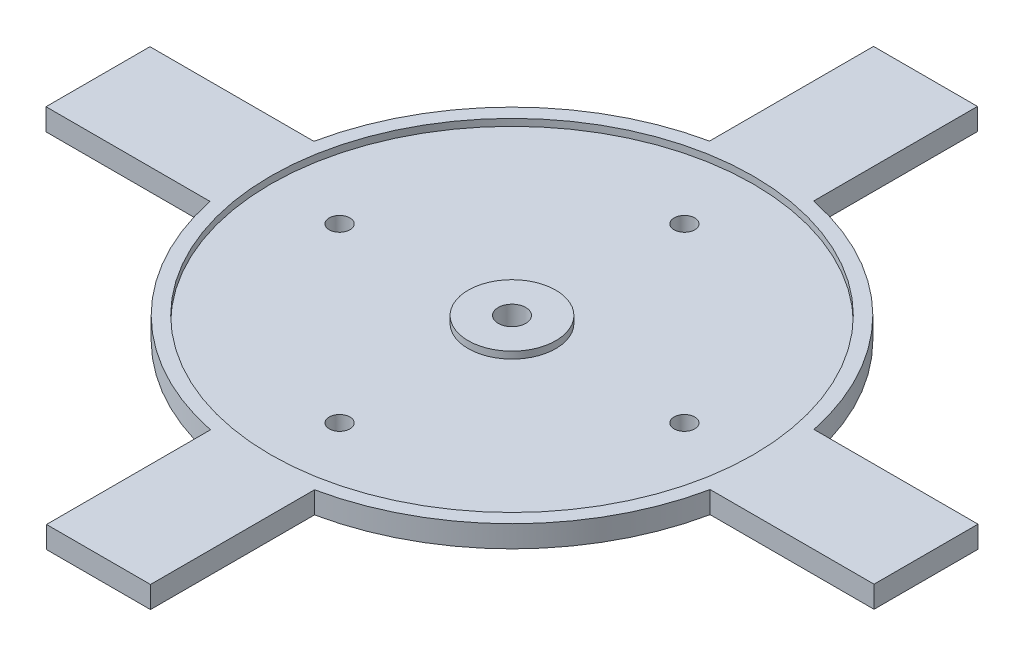
from build123d import *

# Parameters (mm, degrees)
SKETCH1_R           = 37
BOSS_EXTRUDE1_DEPTH = 3.158172797
SKETCH13_W          = 7.575673387
SKETCH13_H          = 3.158172797
SKETCH13_W_2        = 7.5
BOSS_EXTRUDE2_DEPTH = 60
CIRPATTERN1_COUNT   = 4
SKETCH2_R           = 35
SKETCH2_R_2         = 6.35
CUT_EXTRUDE1_DEPTH  = 1
SKETCH17_R          = 2
CUT_EXTRUDE2_DEPTH  = 10
SKETCH19_R          = 1.5
CUT_EXTRUDE3_DEPTH  = 10
CIRPATTERN2_COUNT   = 4


with BuildPart() as part:
    # Sketch1 → Boss-Extrude1 (new body)
    with BuildSketch(Plane(origin=(0, 0, 0), x_dir=(1, 0, 0), z_dir=(0, 1, 0))):
        Circle(SKETCH1_R)
    extrude(amount=BOSS_EXTRUDE1_DEPTH)

    # Sketch13 → Boss-Extrude2 (add)
    with BuildSketch(Plane.XY):
        with Locations((3.787836694, 1.579086399)):
            Rectangle(SKETCH13_W, SKETCH13_H)
        with Locations((-3.75, 1.579086399)):
            Rectangle(SKETCH13_W_2, SKETCH13_H)
    boss_extrude2 = extrude(amount=BOSS_EXTRUDE2_DEPTH)

    # CirPattern1: Boss-Extrude2 ×4 about axis
    cirpattern1_axis = Axis((0, 3.316081437, 0), (0, -1, 0))
    for i in range(1, CIRPATTERN1_COUNT):
        add(boss_extrude2.rotate(cirpattern1_axis, i * 360 / CIRPATTERN1_COUNT))

    # Sketch2 → Cut-Extrude1 (cut)
    with BuildSketch(Plane(origin=(0, 3.158172797, 0), x_dir=(1, 0, 0), z_dir=(0, 1, 0))):
        Circle(SKETCH2_R)
        Circle(SKETCH2_R_2, mode=Mode.SUBTRACT)
    extrude(amount=-CUT_EXTRUDE1_DEPTH, mode=Mode.SUBTRACT)

    # Sketch17 → Cut-Extrude2 (cut)
    with BuildSketch(Plane(origin=(0, 3.158172797, 0), x_dir=(1, 0, 0), z_dir=(0, 1, 0))):
        Circle(SKETCH17_R)
    extrude(amount=-CUT_EXTRUDE2_DEPTH, mode=Mode.SUBTRACT)

    # Sketch19 → Cut-Extrude3 (cut)
    with BuildSketch(Plane(origin=(0, 3.158172797, 0), x_dir=(1, 0, 0), z_dir=(0, 1, 0))):
        with Locations((0, 25)):
            Circle(SKETCH19_R)
    cut_extrude3 = extrude(amount=-CUT_EXTRUDE3_DEPTH, mode=Mode.SUBTRACT)

    # CirPattern2: Cut-Extrude3 ×4 about axis
    cirpattern2_axis = Axis((0, 3.316081437, 0), (0, -1, 0))
    for i in range(1, CIRPATTERN2_COUNT):
        add(cut_extrude3.rotate(cirpattern2_axis, i * 360 / CIRPATTERN2_COUNT), mode=Mode.SUBTRACT)


solid = part.part
